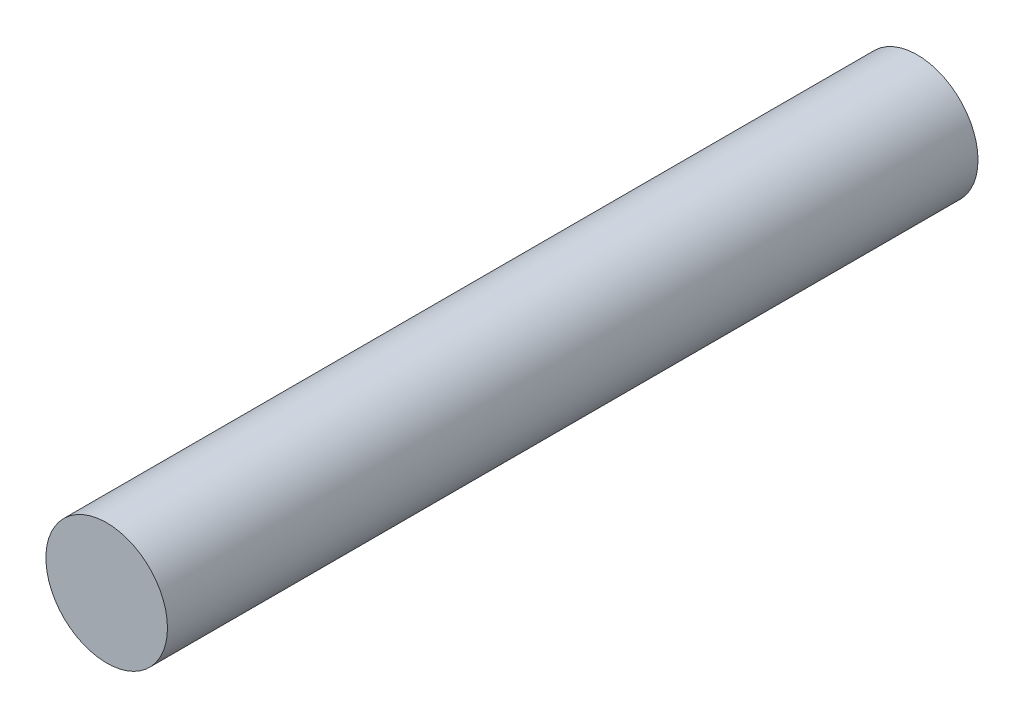
from build123d import *

# Parameters (mm, degrees)
ESQUISSE1_R             = 15
BOSS_EXTRU_1_DEPTH      = 200
ESQUISSE2_W             = 25
ESQUISSE2_H             = 10
ENL_V_MAT_EXTRU_3_DEPTH = 2


with BuildPart() as part:
    # Esquisse1 → Boss.-Extru.1 (new body)
    with BuildSketch(Plane.XY):
        Circle(ESQUISSE1_R)
    extrude(amount=BOSS_EXTRU_1_DEPTH)

    # Esquisse2 → Enlèv. mat.-Extru.3 (cut)
    with BuildSketch(Plane(origin=(0, 0, 0), x_dir=(-1, 0, 0), z_dir=(0, 0, -1))):
        with Locations((-0.5, 0)):
            Rectangle(ESQUISSE2_W, ESQUISSE2_H)
    extrude(amount=-ENL_V_MAT_EXTRU_3_DEPTH, mode=Mode.SUBTRACT)


solid = part.part
